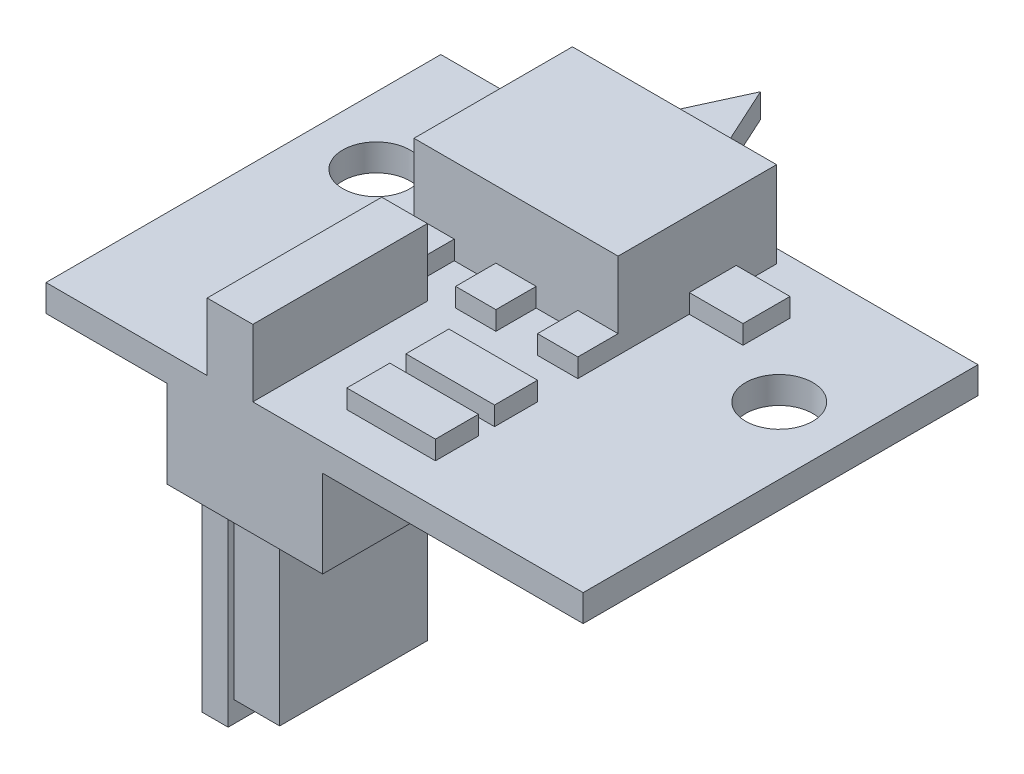
from build123d import *

# Parameters (mm, degrees)
SKETCH_1_W          = 20
SKETCH_1_H          = 14.7
SKETCH_1_R          = 1.25
EXTRUDE_1_DEPTH     = 1
SKETCH_2_W          = 7.6
SKETCH_2_H          = 5.9
EXTRUDE_2_DEPTH     = 3.2
SKETCH_3_W          = 2.93
SKETCH_3_H          = 0.9
EXTRUDE_3_DEPTH     = 3.2
CUT_EXTRUDE_START   = -0.9
CUT_EXTRUDE_1_DEPTH = 0.9
SKETCH_5_W          = 2
SKETCH_5_H          = 1.75
SKETCH_5_W_2        = 1.5
SKETCH_5_H_2        = 1.5
SKETCH_5_W_3        = 3.3
SKETCH_5_H_3        = 1.6
EXTRUDE_4_DEPTH     = 0.7
SKETCH_6_W          = 1.7
SKETCH_6_H          = 6.5
EXTRUDE_5_DEPTH     = 2.5
SKETCH_7_W          = 5.8
SKETCH_7_H          = 7.6
EXTRUDE_6_DEPTH     = 3.25
SKETCH_8_W          = 0.98
SKETCH_8_H          = 5
EXTRUDE_7_DEPTH     = 8
SKETCH_9_W          = 1.7
SKETCH_9_H          = 5.5
EXTRUDE_8_DEPTH     = 6.7


with BuildPart() as part:
    # 草图1 → 凸台-拉伸1 (new body)
    with BuildSketch(Plane(origin=(0, 0, 0), x_dir=(1, 0, 0), z_dir=(0, 1, 0))):
        with Locations((0, -2.45)):
            Rectangle(SKETCH_1_W, SKETCH_1_H)
        with Locations((-7.5, 0)):
            Circle(SKETCH_1_R, mode=Mode.SUBTRACT)
        with Locations((7.5, 0)):
            Circle(SKETCH_1_R, mode=Mode.SUBTRACT)
    extrude(amount=EXTRUDE_1_DEPTH)

    # 草图2 → 凸台-拉伸2 (add)
    with BuildSketch(Plane(origin=(0, 1, 0), x_dir=(1, 0, 0), z_dir=(0, 1, 0))):
        with Locations((-0.8, 1.45)):
            Rectangle(SKETCH_2_W, SKETCH_2_H)
    extrude(amount=EXTRUDE_2_DEPTH)

    # 草图3 → 凸台-拉伸3 (add)
    with BuildSketch(Plane(origin=(0, 0, -4.4), x_dir=(-1, 0, 0), z_dir=(0, 0, -1))):
        with Locations((0.8, 2.6)):
            Rectangle(SKETCH_3_W, SKETCH_3_H)
    extrude(amount=EXTRUDE_3_DEPTH)

    # 草图4 → 切除-拉伸1 (cut)
    with BuildSketch(Plane(origin=(0, 3.05, 0), x_dir=(1, 0, 0), z_dir=(0, 1, 0)).offset(CUT_EXTRUDE_START)):
        Polygon((-0.8, 7.6), (-2.265, 4.4), (-2.265, 7.6), (-2.265, 7.984995913), (0.665, 7.984995913), (0.665, 7.6), (0.665, 4.4), align=None)
    extrude(amount=CUT_EXTRUDE_1_DEPTH, mode=Mode.SUBTRACT)

    # 草图5 → 凸台-拉伸4 (add)
    with BuildSketch(Plane(origin=(0, 1, 0), x_dir=(1, 0, 0), z_dir=(0, 1, 0))):
        with Locations((4, 2.025)):
            Rectangle(SKETCH_5_W, SKETCH_5_H)
        with Locations((-5.6, 2.025)):
            Rectangle(SKETCH_5_W, SKETCH_5_H)
        with Locations((-3.85, -2.25)):
            Rectangle(SKETCH_5_W_2, SKETCH_5_H_2)
        with Locations((-0.8, -2.25)):
            Rectangle(SKETCH_5_W_2, SKETCH_5_H_2)
        with Locations((2.25, -2.25)):
            Rectangle(SKETCH_5_W_2, SKETCH_5_H_2)
        with Locations((1.35, -5.3)):
            Rectangle(SKETCH_5_W_3, SKETCH_5_H_3)
        with Locations((1.35, -7.5)):
            Rectangle(SKETCH_5_W_3, SKETCH_5_H_3)
    extrude(amount=EXTRUDE_4_DEPTH)

    # 草图6 → 凸台-拉伸5 (add)
    with BuildSketch(Plane(origin=(0, 1, 0), x_dir=(1, 0, 0), z_dir=(0, 1, 0))):
        with Locations((-3.15, -6.55)):
            Rectangle(SKETCH_6_W, SKETCH_6_H)
    extrude(amount=EXTRUDE_5_DEPTH)

    # 草图7 → 凸台-拉伸6 (add)
    with BuildSketch(Plane.XZ):
        with Locations((-2.6, 6)):
            Rectangle(SKETCH_7_W, SKETCH_7_H)
    extrude(amount=EXTRUDE_6_DEPTH)

    # 草图8 → 凸台-拉伸7 (add)
    with BuildSketch(Plane.XZ.offset(3.25)):
        with Locations((-5.01, 6)):
            Rectangle(SKETCH_8_W, SKETCH_8_H)
    extrude(amount=EXTRUDE_7_DEPTH)

    # 草图9 → 凸台-拉伸8 (add)
    with BuildSketch(Plane.XZ.offset(3.25)):
        with Locations((-3.15, 6.05)):
            Rectangle(SKETCH_9_W, SKETCH_9_H)
    extrude(amount=EXTRUDE_8_DEPTH)


solid = part.part
